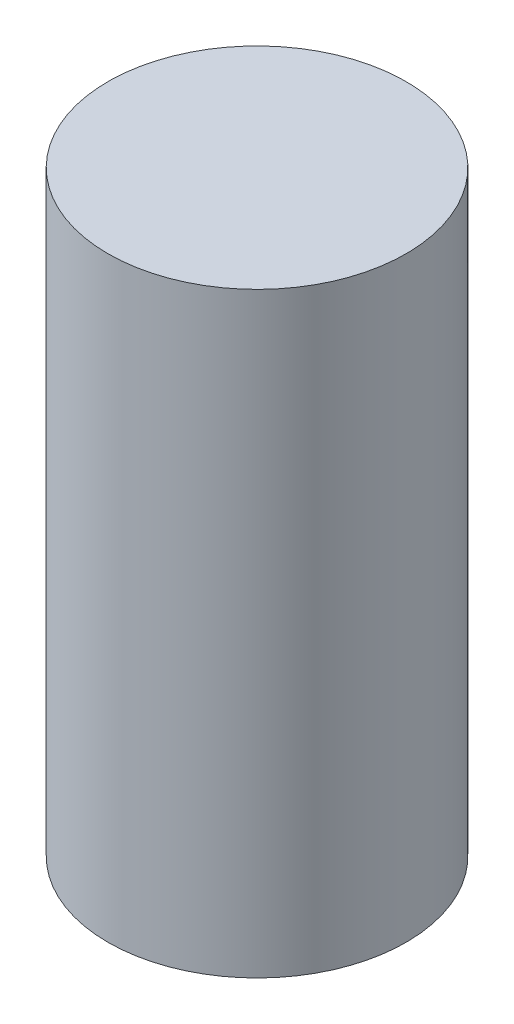
from build123d import *

# Parameters (mm, degrees)
SKETCH1_R           = 1.5875
BOSS_EXTRUDE1_DEPTH = 6.35


with BuildPart() as part:
    # Sketch1 → Boss-Extrude1 (new body)
    with BuildSketch(Plane(origin=(0, 0, 0), x_dir=(1, 0, 0), z_dir=(0, 1, 0))):
        Circle(SKETCH1_R)
    extrude(amount=BOSS_EXTRUDE1_DEPTH)


solid = part.part
